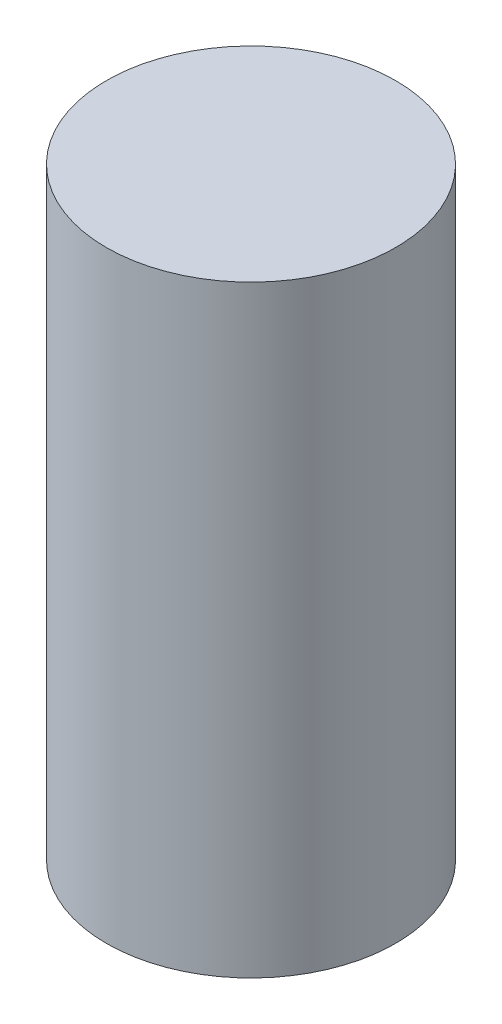
from build123d import *

# Parameters (mm, degrees)
SKETCH1_R           = 0.762
BOSS_EXTRUDE1_DEPTH = 1.5875


with BuildPart() as part:
    # Sketch1 → Boss-Extrude1 (new body, symmetric)
    with BuildSketch(Plane(origin=(0, 0, 0), x_dir=(1, 0, 0), z_dir=(0, 1, 0))):
        with Locations(Location((0, 0, 0), (0, 0, 270))):  # turned: the seam where the file's is
            Circle(SKETCH1_R)
    extrude(amount=BOSS_EXTRUDE1_DEPTH, both=True)


solid = part.part
